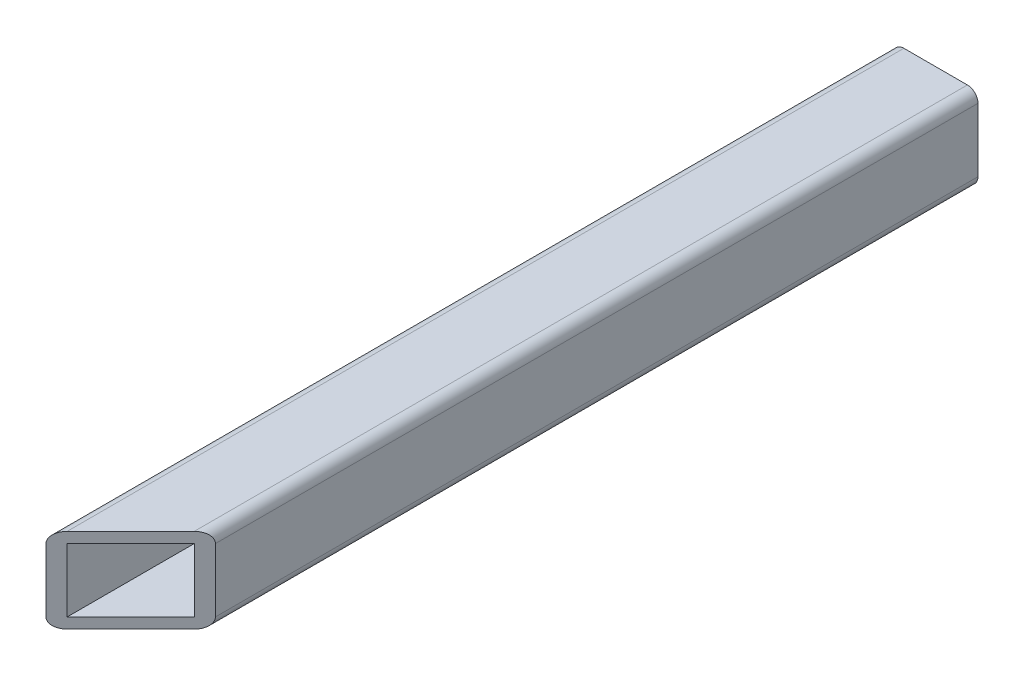
from build123d import *

# Parameters (mm, degrees)
SKETCH1_W           = 12.7
SKETCH1_H           = 12.7
SKETCH1_W_2         = 9.525
SKETCH1_H_2         = 9.525
BOSS_EXTRUDE1_DEPTH = 127
CUT_EXTRUDE1_DEPTH  = 13.7
FILLET1_R           = 1.5875


with BuildPart() as part:
    # Sketch1 → Boss-Extrude1 (new body)
    with BuildSketch(Plane.XY):
        with Locations((6.35, 6.35)):
            Rectangle(SKETCH1_W, SKETCH1_H)
        with Locations((6.35, 6.35)):
            Rectangle(SKETCH1_W_2, SKETCH1_H_2, mode=Mode.SUBTRACT)
    extrude(amount=BOSS_EXTRUDE1_DEPTH)

    # Sketch2 → Cut-Extrude1 (cut, through all)
    with BuildSketch(Plane(origin=(0, 12.7, 0), x_dir=(1, 0, 0), z_dir=(0, 1, 0))):
        Polygon((0, -127), (12.7, -127), (12.7, -114.3), align=None)
    extrude(amount=-CUT_EXTRUDE1_DEPTH, mode=Mode.SUBTRACT)

    # Fillet1
    fillet1_edges = [part.edges().sort_by_distance(p)[0] for p in [
        (12.7, 12.7, 57.15),
        (12.7, 0, 57.15),
        (0, 12.7, 63.5),
        (0, 0, 63.5),
    ]]
    fillet(fillet1_edges, radius=FILLET1_R)


solid = part.part
